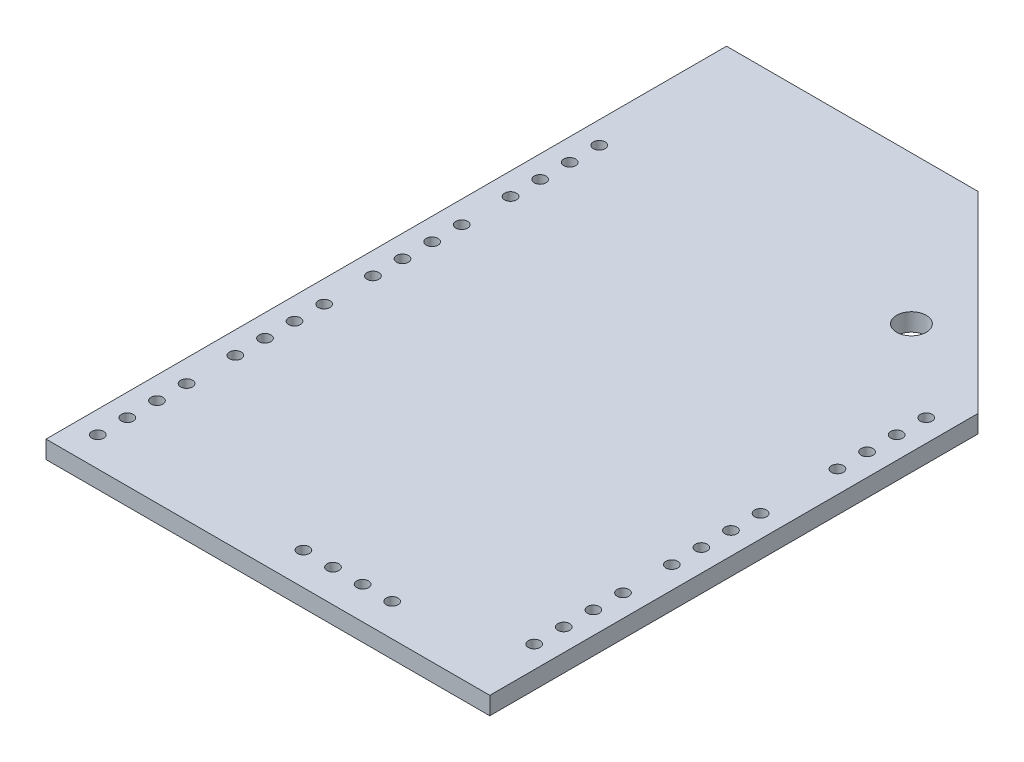
from build123d import *

# Parameters (mm, degrees)
BOSS_EXTRUDE1_DEPTH = 1.2
CUT_EXTRUDE1_REACH  = 3.2
SKETCH2_R           = 1
SKETCH3_R           = 0.4
CUT_EXTRUDE2_DEPTH  = 1.2
LPATTERN1_COUNT     = 4
LPATTERN1_PITCH     = 9.3
SKETCH4_R           = 0.4
CUT_EXTRUDE3_DEPTH  = 1.2
LPATTERN2_COUNT     = 2
LPATTERN2_PITCH     = 9.3
LPATTERN3_COUNT     = 2
LPATTERN3_PITCH     = 20.5
CUT_EXTRUDE4_REACH  = 3.2
SKETCH5_R           = 0.4


with BuildPart() as part:
    # Sketch1 → Boss-Extrude1 (new body)
    with BuildSketch(Plane(origin=(0, 0, 0), x_dir=(1, 0, 0), z_dir=(0, 1, 0))):
        Polygon((0, 0), (0, 46), (17, 46), (30, 33), (30, 0), align=None)
    extrude(amount=BOSS_EXTRUDE1_DEPTH)

    # Sketch2 → Cut-Extrude1 (cut, up to next)
    with BuildSketch(Plane(origin=(0, 1.2, 0), x_dir=(1, 0, 0), z_dir=(0, 1, 0)), mode=Mode.PRIVATE) as cut_extrude1_sk1:
        with Locations((22.5, 36)):
            Circle(SKETCH2_R)
    cut_extrude1_tool1 = extrude(cut_extrude1_sk1.sketch, amount=-CUT_EXTRUDE1_REACH, mode=Mode.PRIVATE) & part.part
    add(cut_extrude1_tool1.solids().sort_by_distance((22.5, 1.2, -36))[0], mode=Mode.SUBTRACT)

    # Sketch3 → Cut-Extrude2 (cut)
    with BuildSketch(Plane(origin=(0, 1.2, 0), x_dir=(1, 0, 0), z_dir=(0, 1, 0))):
        with Locations((1.5, 2)):
            Circle(SKETCH3_R)
        with Locations((1.5, 4)):
            Circle(SKETCH3_R)
        with Locations((1.5, 6)):
            Circle(SKETCH3_R)
        with Locations((1.5, 8)):
            Circle(SKETCH3_R)
    cut_extrude2 = extrude(amount=-CUT_EXTRUDE2_DEPTH, mode=Mode.SUBTRACT)

    # LPattern1: Cut-Extrude2 ×4
    with Locations(*[(0, 0, -i * LPATTERN1_PITCH) for i in range(1, LPATTERN1_COUNT)]):
        add(cut_extrude2, mode=Mode.SUBTRACT)

    # Sketch4 → Cut-Extrude3 (cut)
    with BuildSketch(Plane(origin=(0, 1.2, 0), x_dir=(1, 0, 0), z_dir=(0, 1, 0))):
        with Locations((28.5, 4.5)):
            Circle(SKETCH4_R)
        with Locations((28.5, 6.5)):
            Circle(SKETCH4_R)
        with Locations((28.5, 8.5)):
            Circle(SKETCH4_R)
        with Locations((28.5, 10.5)):
            Circle(SKETCH4_R)
    cut_extrude3 = extrude(amount=-CUT_EXTRUDE3_DEPTH, mode=Mode.SUBTRACT)

    # LPattern2: Cut-Extrude3 ×2
    with Locations(*[(0, 0, -i * LPATTERN2_PITCH) for i in range(1, LPATTERN2_COUNT)]):
        add(cut_extrude3, mode=Mode.SUBTRACT)

    # LPattern3: Cut-Extrude3 ×2
    with Locations(*[(0, 0, -i * LPATTERN3_PITCH) for i in range(1, LPATTERN3_COUNT)]):
        add(cut_extrude3, mode=Mode.SUBTRACT)

    # Sketch5 → Cut-Extrude4 (cut, up to next)
    with BuildSketch(Plane(origin=(0, 1.2, 0), x_dir=(1, 0, 0), z_dir=(0, 1, 0)), mode=Mode.PRIVATE) as cut_extrude4_sk1:
        with Locations((15.2, 2.2)):
            Circle(SKETCH5_R)
    cut_extrude4_tool1 = extrude(cut_extrude4_sk1.sketch, amount=-CUT_EXTRUDE4_REACH, mode=Mode.PRIVATE) & part.part
    add(cut_extrude4_tool1.solids().sort_by_distance((15.2, 1.2, -2.2))[0], mode=Mode.SUBTRACT)
    # Sketch5 → Cut-Extrude4 (cut, up to next)
    with BuildSketch(Plane(origin=(0, 1.2, 0), x_dir=(1, 0, 0), z_dir=(0, 1, 0)), mode=Mode.PRIVATE) as cut_extrude4_sk2:
        with Locations((17.2, 2.2)):
            Circle(SKETCH5_R)
    cut_extrude4_tool2 = extrude(cut_extrude4_sk2.sketch, amount=-CUT_EXTRUDE4_REACH, mode=Mode.PRIVATE) & part.part
    add(cut_extrude4_tool2.solids().sort_by_distance((17.2, 1.2, -2.2))[0], mode=Mode.SUBTRACT)
    # Sketch5 → Cut-Extrude4 (cut, up to next)
    with BuildSketch(Plane(origin=(0, 1.2, 0), x_dir=(1, 0, 0), z_dir=(0, 1, 0)), mode=Mode.PRIVATE) as cut_extrude4_sk3:
        with Locations((19.2, 2.2)):
            Circle(SKETCH5_R)
    cut_extrude4_tool3 = extrude(cut_extrude4_sk3.sketch, amount=-CUT_EXTRUDE4_REACH, mode=Mode.PRIVATE) & part.part
    add(cut_extrude4_tool3.solids().sort_by_distance((19.2, 1.2, -2.2))[0], mode=Mode.SUBTRACT)
    # Sketch5 → Cut-Extrude4 (cut, up to next)
    with BuildSketch(Plane(origin=(0, 1.2, 0), x_dir=(1, 0, 0), z_dir=(0, 1, 0)), mode=Mode.PRIVATE) as cut_extrude4_sk4:
        with Locations((21.2, 2.2)):
            Circle(SKETCH5_R)
    cut_extrude4_tool4 = extrude(cut_extrude4_sk4.sketch, amount=-CUT_EXTRUDE4_REACH, mode=Mode.PRIVATE) & part.part
    add(cut_extrude4_tool4.solids().sort_by_distance((21.2, 1.2, -2.2))[0], mode=Mode.SUBTRACT)


solid = part.part
